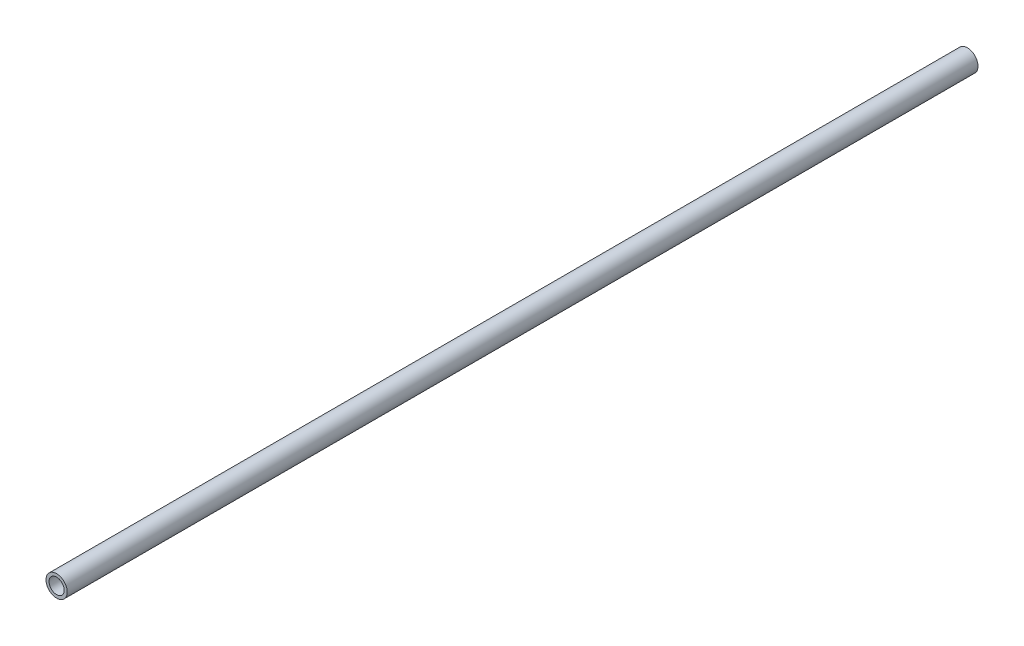
from build123d import *

# Parameters (mm, degrees)
SKETCH1_R           = 3.5
SKETCH1_R_2         = 2.5
BOSS_EXTRUDE1_DEPTH = 150


with BuildPart() as part:
    # Sketch1 → Boss-Extrude1 (new body, symmetric)
    with BuildSketch(Plane.XY):
        with Locations((47.917075251, 71.548323893)):
            Circle(SKETCH1_R)
        with Locations((47.917075251, 71.548323893)):
            Circle(SKETCH1_R_2, mode=Mode.SUBTRACT)
    extrude(amount=BOSS_EXTRUDE1_DEPTH, both=True)


solid = part.part
